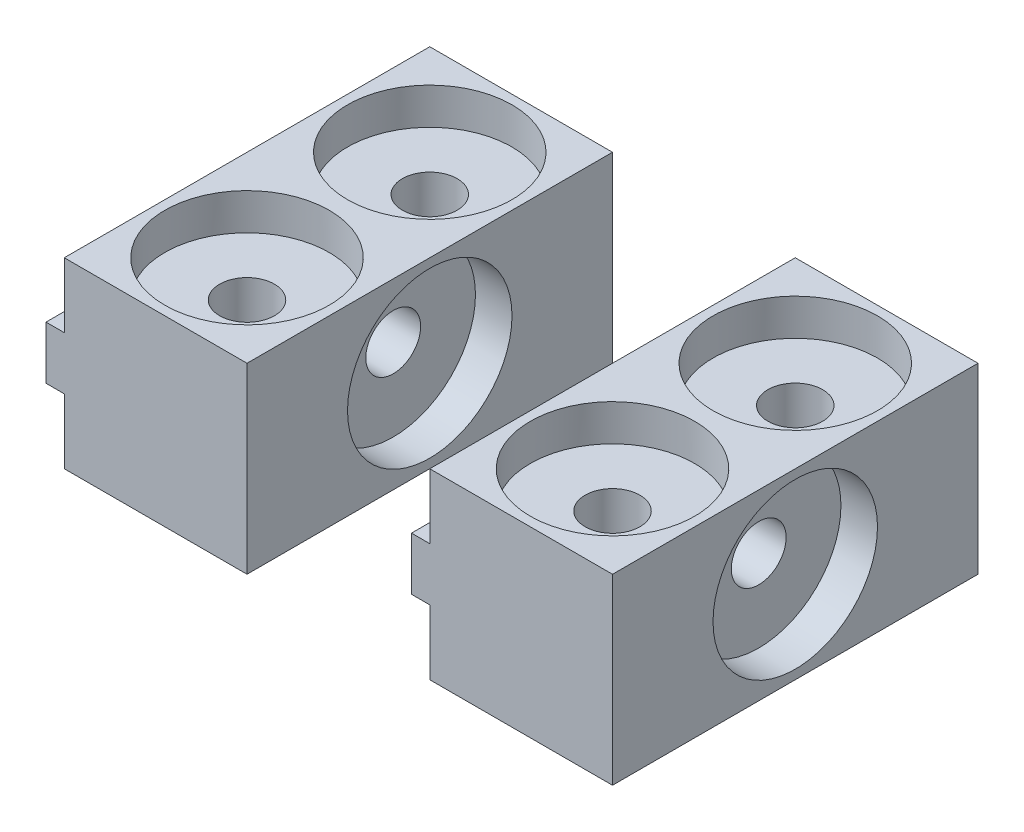
from build123d import *

# Parameters (mm, degrees)
BOSS_EXTRUDE1_DEPTH = 20
SKETCH2_R           = 1.5
CUT_EXTRUDE1_DEPTH  = 11
SKETCH3_R           = 4.5
CUT_EXTRUDE2_DEPTH  = 2
SKETCH4_R           = 1.5
CUT_EXTRUDE3_DEPTH  = 10
SKETCH6_R           = 4.5
CUT_EXTRUDE4_DEPTH  = 2
LPATTERN1_COUNT     = 2
LPATTERN1_PITCH     = 10
LPATTERN3_COUNT     = 2
LPATTERN3_PITCH     = 20


with BuildPart() as part:
    # Sketch1 → Boss-Extrude1 (new body)
    with BuildSketch(Plane.XY):
        Polygon((-10, 0), (-10, -3.55), (-11, -3.55), (-11, -6.45), (-10, -6.45), (-10, -10), (0, -10), (0, 0), align=None)
    extrude(amount=BOSS_EXTRUDE1_DEPTH)

    # Sketch2 → Cut-Extrude1 (cut, through all)
    with BuildSketch(Plane(origin=(0, 0, 0), x_dir=(1, 0, 0), z_dir=(0, 1, 0))):
        with Locations((-5, -15)):
            Circle(SKETCH2_R)
    cut_extrude1 = extrude(amount=-CUT_EXTRUDE1_DEPTH, mode=Mode.SUBTRACT)

    # Sketch3 → Cut-Extrude2 (cut)
    with BuildSketch(Plane(origin=(0, 0, 0), x_dir=(0, 0, -1), z_dir=(1, 0, 0))):
        with Locations((-10, -5)):
            Circle(SKETCH3_R)
    extrude(amount=-CUT_EXTRUDE2_DEPTH, mode=Mode.SUBTRACT)

    # Sketch4 → Cut-Extrude3 (cut, through all)
    with BuildSketch(Plane(origin=(-2, 0, 0), x_dir=(0, 0, -1), z_dir=(1, 0, 0))):
        with Locations((-10, -5)):
            Circle(SKETCH4_R)
    extrude(amount=-CUT_EXTRUDE3_DEPTH, mode=Mode.SUBTRACT)

    # Sketch6 → Cut-Extrude4 (cut)
    with BuildSketch(Plane(origin=(0, 0, 0), x_dir=(1, 0, 0), z_dir=(0, 1, 0))):
        with Locations((-5, -15)):
            Circle(SKETCH6_R)
    cut_extrude4 = extrude(amount=-CUT_EXTRUDE4_DEPTH, mode=Mode.SUBTRACT)

    # LPattern1: Cut-Extrude1, Cut-Extrude4 ×2
    with Locations(*[(0, 0, -i * LPATTERN1_PITCH) for i in range(1, LPATTERN1_COUNT)]):
        add(cut_extrude1, mode=Mode.SUBTRACT)
        add(cut_extrude4, mode=Mode.SUBTRACT)


with BuildPart() as lpattern3_1:
    # LPattern3: pattern copy
    add(part.part.moved(Location(Vector(-1, 0, 0) * (1 * LPATTERN3_PITCH))))


solid = Compound([part.part, lpattern3_1.part])
